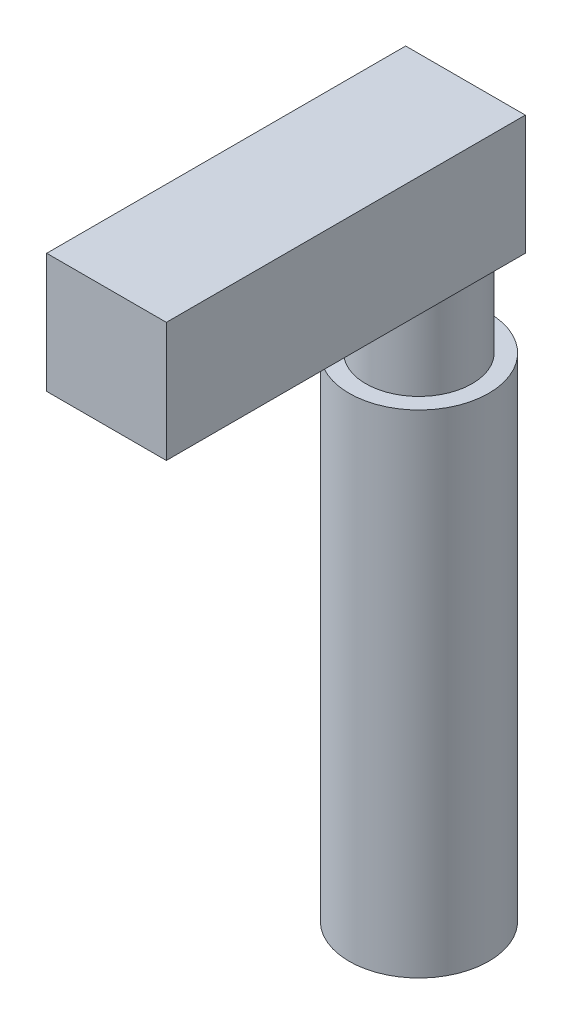
from build123d import *

# Parameters (mm, degrees)
SKETCH_1_W      = 9
SKETCH_1_H      = 9
EXTRUDE_1_DEPTH = 27
SKETCH_2_R      = 4
EXTRUDE_2_DEPTH = 7
SKETCH_3_R      = 5.25
EXTRUDE_3_DEPTH = 37


with BuildPart() as part:
    # 草图1 → 凸台-拉伸1 (new body)
    with BuildSketch(Plane.XY):
        with Locations((-4.5, 4.5)):
            Rectangle(SKETCH_1_W, SKETCH_1_H)
    extrude(amount=EXTRUDE_1_DEPTH)

    # 草图2 → 凸台-拉伸2 (add)
    with BuildSketch(Plane.XZ):
        with Locations((-4.5, 3.5)):
            Circle(SKETCH_2_R)
    extrude(amount=EXTRUDE_2_DEPTH)

    # 草图3 → 凸台-拉伸3 (add)
    with BuildSketch(Plane.XZ.offset(7)):
        with Locations((-4.5, 3.5)):
            Circle(SKETCH_3_R)
    extrude(amount=EXTRUDE_3_DEPTH)


solid = part.part
